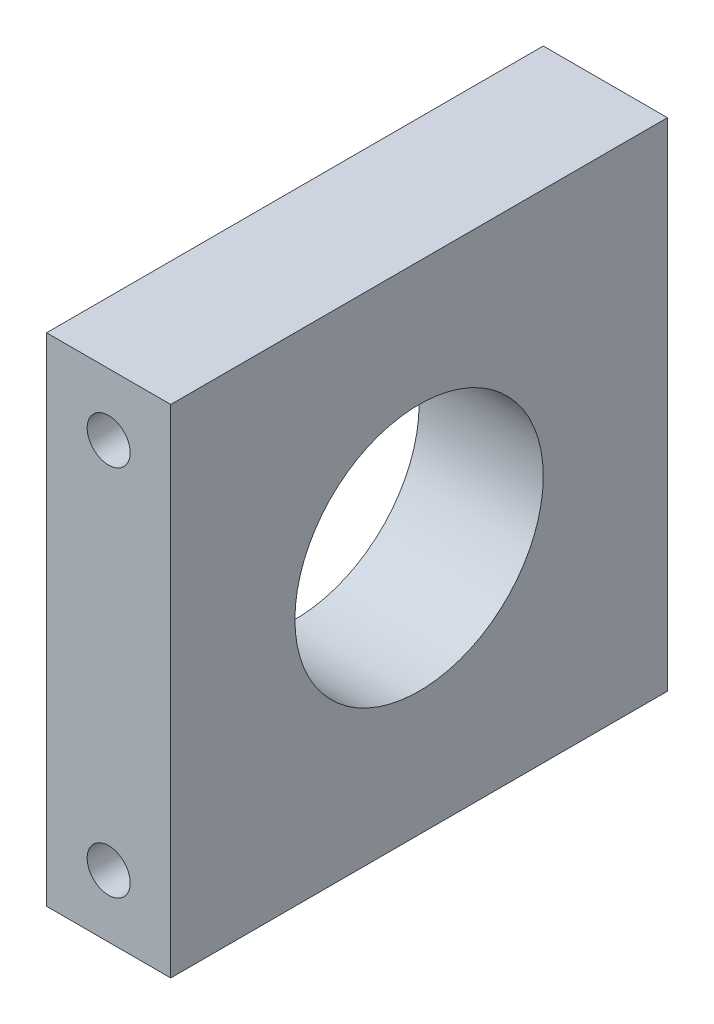
from build123d import *

# Parameters (mm, degrees)
SKETCH2_W             = 38.1
SKETCH2_H             = 38.1
SKETCH2_R             = 9.525
BOSS_EXTRUDE1_DEPTH   = 9.525
M4X0_7_TAPPED_HOLE1_D = 3.3


with BuildPart() as part:
    # Sketch2 → Boss-Extrude1 (new body)
    with BuildSketch(Plane(origin=(0, 0, 0), x_dir=(0, 0, -1), z_dir=(1, 0, 0))):
        with Locations((19.05, 19.05)):
            Rectangle(SKETCH2_W, SKETCH2_H)
        with Locations((19.05, 19.05)):
            Circle(SKETCH2_R, mode=Mode.SUBTRACT)
    extrude(amount=BOSS_EXTRUDE1_DEPTH)

    # M4x0.7 Tapped Hole1 (through all)
    with Locations(Plane(origin=(0, 0, -38.1), x_dir=(-1, 0, 0), z_dir=(0, 0, -1))):
        with Locations((-4.7625, 33.3375), (-4.7625, 4.7625)):
            Hole(M4X0_7_TAPPED_HOLE1_D / 2)


solid = part.part
